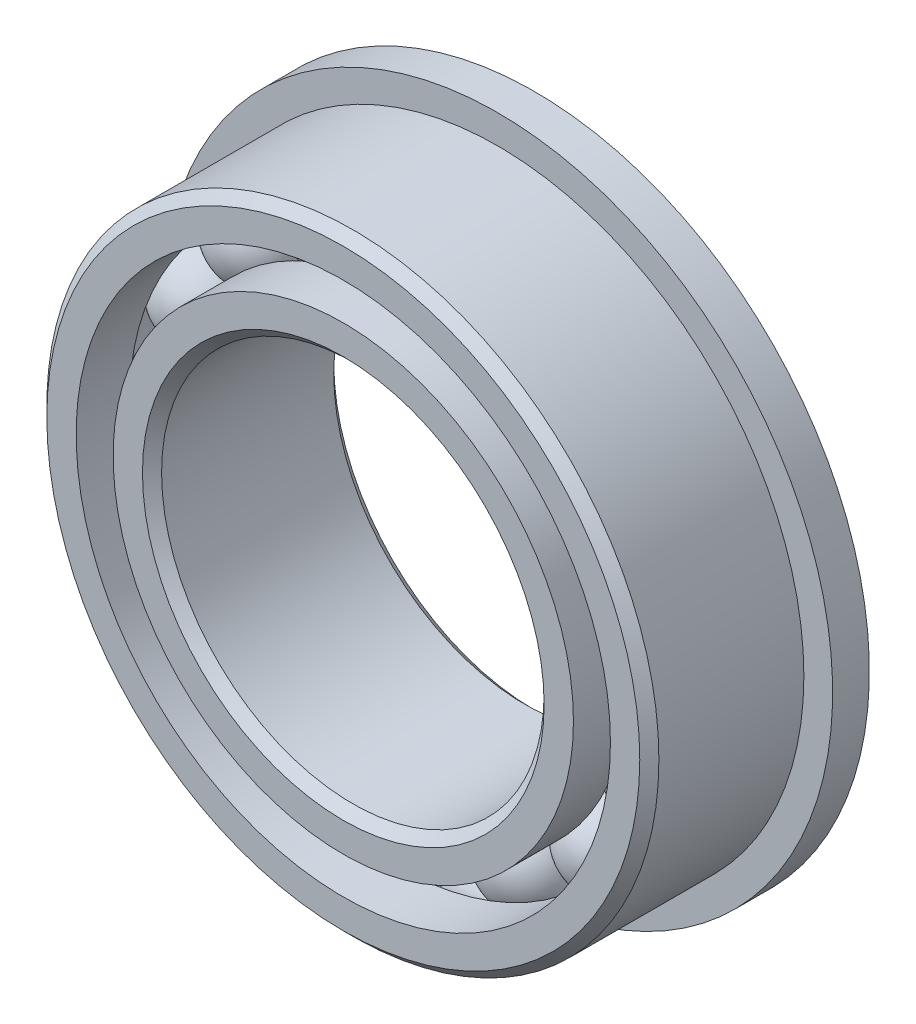
from build123d import *

# Parameters (mm, degrees)
SKETCH5_W         = 0.762
SKETCH5_H         = 1.099535646
CIRPATTERN1_COUNT = 16


with BuildPart() as part:
    # Sketch1 → Revolve1 (revolve)
    with BuildSketch(Plane(origin=(0, 0, 0), x_dir=(0, 0, -1), z_dir=(1, 0, 0))):
        with BuildLine():
            Line((1.7859375, 6.35), (-1.7859375, 6.35))
            Line((-1.7859375, 6.35), (-1.984375, 6.1515625))
            Line((-1.984375, 6.1515625), (-1.984375, 5.543166209))
            Line((-1.984375, 5.543166209), (-0.881944444, 5.543166209))
            ThreePointArc((-0.881944444, 5.543166209), (0, 6.121207467), (0.881944444, 5.543166209))
            Line((0.881944444, 5.543166209), (1.984375, 5.543166209))
            Line((1.984375, 5.543166209), (1.984375, 6.1515625))
            Line((1.984375, 6.1515625), (1.7859375, 6.35))
        make_face()
    revolve(axis=Axis((0, 0, 1.984375), (0, 0, -1)))

    # Sketch5 → Revolve5 (revolve)
    with BuildSketch(Plane(origin=(0, 0, 0), x_dir=(0, 0, -1), z_dir=(1, 0, 0))):
        with Locations((1.603375, 6.397132177)):
            Rectangle(SKETCH5_W, SKETCH5_H)
    revolve(axis=Axis((0, 0, -1.984375), (0, 0, 1)))


with BuildPart() as body_2:
    # Sketch3 → Revolve3 (revolve)
    with BuildSketch(Plane(origin=(0, 0, 0), x_dir=(0, 0, -1), z_dir=(1, 0, 0))):
        with BuildLine():
            Line((-0.881944444, 4.775583791), (-1.984375, 4.775583791))
            Line((-1.984375, 4.775583791), (-1.984375, 4.1671875))
            Line((-1.984375, 4.1671875), (-1.7859375, 3.96875))
            Line((-1.7859375, 3.96875), (1.7859375, 3.96875))
            Line((1.7859375, 3.96875), (1.984375, 4.1671875))
            Line((1.984375, 4.1671875), (1.984375, 4.775583791))
            Line((1.984375, 4.775583791), (0.881944444, 4.775583791))
            ThreePointArc((0.881944444, 4.775583791), (0, 4.197542533), (-0.881944444, 4.775583791))
        make_face()
    revolve(axis=Axis((0, 0, 1.984375), (0, 0, -1)))


with BuildPart() as body_3:
    # Sketch4 → Revolve4 (revolve)
    with BuildSketch(Plane(origin=(0, 0, 0), x_dir=(0, 0, -1), z_dir=(1, 0, 0))):
        with BuildLine():
            Line((-0.961832467, 5.159375), (0.961832467, 5.159375))
            ThreePointArc((0.961832467, 5.159375), (0, 6.121207467), (-0.961832467, 5.159375))
        make_face()
    revolve(axis=Axis((0, 5.159375, 0.961832467), (0, 0, -1)))


with BuildPart() as cirpattern1_1:
    # CirPattern1: pattern copy
    add(body_3.part.rotate(Axis((0, 0, -1.984375), (0, 0, 1)), 1 * 360 / CIRPATTERN1_COUNT))


with BuildPart() as cirpattern1_2:
    # CirPattern1: pattern copy
    add(body_3.part.rotate(Axis((0, 0, -1.984375), (0, 0, 1)), 2 * 360 / CIRPATTERN1_COUNT))


with BuildPart() as cirpattern1_3:
    # CirPattern1: pattern copy
    add(body_3.part.rotate(Axis((0, 0, -1.984375), (0, 0, 1)), 3 * 360 / CIRPATTERN1_COUNT))


with BuildPart() as cirpattern1_4:
    # CirPattern1: pattern copy
    add(body_3.part.rotate(Axis((0, 0, -1.984375), (0, 0, 1)), 4 * 360 / CIRPATTERN1_COUNT))


with BuildPart() as cirpattern1_5:
    # CirPattern1: pattern copy
    add(body_3.part.rotate(Axis((0, 0, -1.984375), (0, 0, 1)), 5 * 360 / CIRPATTERN1_COUNT))


with BuildPart() as cirpattern1_6:
    # CirPattern1: pattern copy
    add(body_3.part.rotate(Axis((0, 0, -1.984375), (0, 0, 1)), 6 * 360 / CIRPATTERN1_COUNT))


with BuildPart() as cirpattern1_7:
    # CirPattern1: pattern copy
    add(body_3.part.rotate(Axis((0, 0, -1.984375), (0, 0, 1)), 7 * 360 / CIRPATTERN1_COUNT))


with BuildPart() as cirpattern1_8:
    # CirPattern1: pattern copy
    add(body_3.part.rotate(Axis((0, 0, -1.984375), (0, 0, 1)), 8 * 360 / CIRPATTERN1_COUNT))


with BuildPart() as cirpattern1_9:
    # CirPattern1: pattern copy
    add(body_3.part.rotate(Axis((0, 0, -1.984375), (0, 0, 1)), 9 * 360 / CIRPATTERN1_COUNT))


with BuildPart() as cirpattern1_10:
    # CirPattern1: pattern copy
    add(body_3.part.rotate(Axis((0, 0, -1.984375), (0, 0, 1)), 10 * 360 / CIRPATTERN1_COUNT))


with BuildPart() as cirpattern1_11:
    # CirPattern1: pattern copy
    add(body_3.part.rotate(Axis((0, 0, -1.984375), (0, 0, 1)), 11 * 360 / CIRPATTERN1_COUNT))


with BuildPart() as cirpattern1_12:
    # CirPattern1: pattern copy
    add(body_3.part.rotate(Axis((0, 0, -1.984375), (0, 0, 1)), 12 * 360 / CIRPATTERN1_COUNT))


with BuildPart() as cirpattern1_13:
    # CirPattern1: pattern copy
    add(body_3.part.rotate(Axis((0, 0, -1.984375), (0, 0, 1)), 13 * 360 / CIRPATTERN1_COUNT))


with BuildPart() as cirpattern1_14:
    # CirPattern1: pattern copy
    add(body_3.part.rotate(Axis((0, 0, -1.984375), (0, 0, 1)), 14 * 360 / CIRPATTERN1_COUNT))


with BuildPart() as cirpattern1_15:
    # CirPattern1: pattern copy
    add(body_3.part.rotate(Axis((0, 0, -1.984375), (0, 0, 1)), 15 * 360 / CIRPATTERN1_COUNT))


solid = Compound([part.part, body_2.part, body_3.part, cirpattern1_1.part, cirpattern1_2.part, cirpattern1_3.part, cirpattern1_4.part, cirpattern1_5.part, cirpattern1_6.part, cirpattern1_7.part, cirpattern1_8.part, cirpattern1_9.part, cirpattern1_10.part, cirpattern1_11.part, cirpattern1_12.part, cirpattern1_13.part, cirpattern1_14.part, cirpattern1_15.part])
